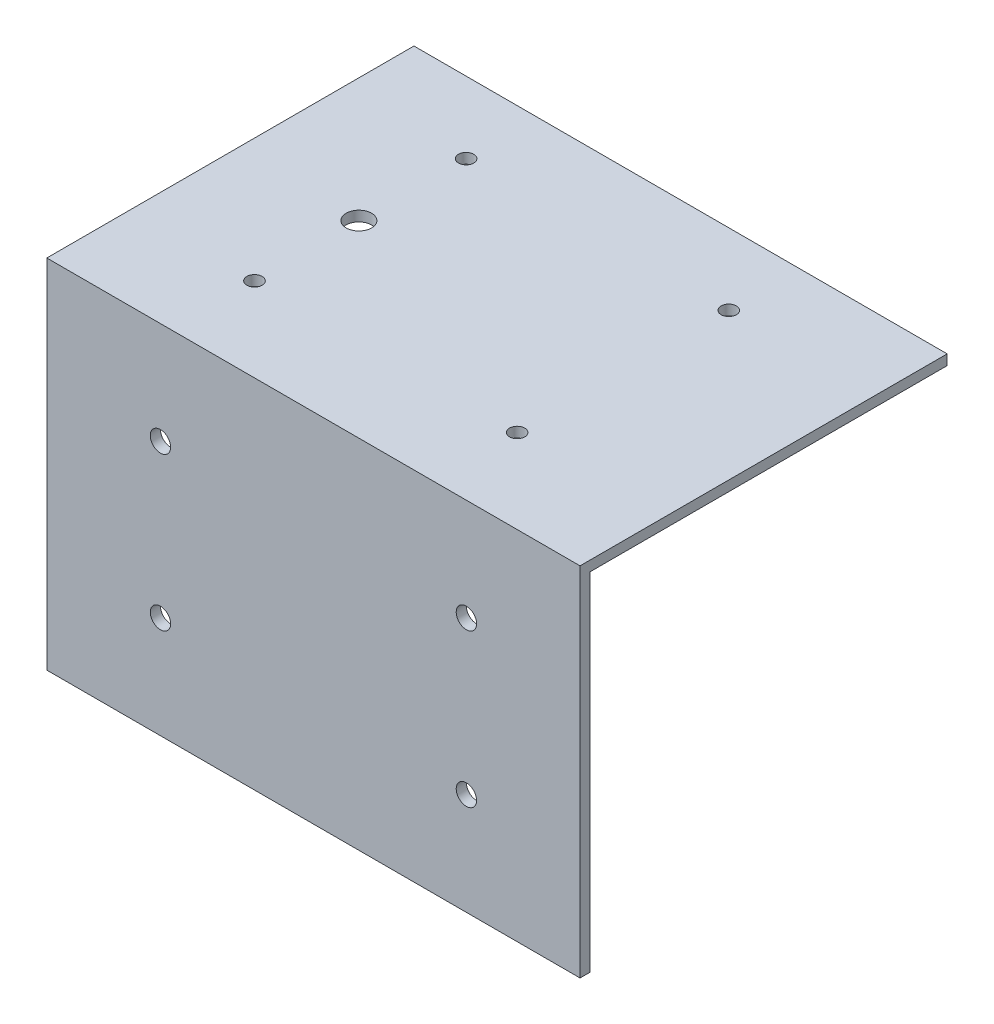
from build123d import *

# Parameters (mm, degrees)
SKETCH1_W           = 100
SKETCH1_H           = 70
SKETCH1_R           = 1.5
SKETCH1_R_2         = 2.5
BOSS_EXTRUDE1_DEPTH = 2
SKETCH2_W           = 70
SKETCH2_H           = 2
BOSS_EXTRUDE2_DEPTH = 70
SKETCH3_W           = 70
SKETCH3_H           = 2
BOSS_EXTRUDE3_DEPTH = 4.57
SKETCH4_W           = 34.57
SKETCH4_H           = 2
BOSS_EXTRUDE4_DEPTH = 70
SKETCH5_R           = 2
CUT_EXTRUDE1_DEPTH  = 10


with BuildPart() as part:
    # Sketch1 → Boss-Extrude1 (new body)
    with BuildSketch(Plane(origin=(0, 0, 0), x_dir=(1, 0, 0), z_dir=(0, 1, 0))):
        Rectangle(SKETCH1_W, SKETCH1_H)
        with Locations((25.755, 20.98)):
            Circle(SKETCH1_R, mode=Mode.SUBTRACT)
        with Locations((-25.755, 20.98)):
            Circle(SKETCH1_R, mode=Mode.SUBTRACT)
        with Locations((25.755, -20.52)):
            Circle(SKETCH1_R, mode=Mode.SUBTRACT)
        with Locations((-25.755, -20.52)):
            Circle(SKETCH1_R, mode=Mode.SUBTRACT)
        with Locations((-25.755, -0.05)):
            Circle(SKETCH1_R_2, mode=Mode.SUBTRACT)
    extrude(amount=BOSS_EXTRUDE1_DEPTH)

    # Sketch2 → Boss-Extrude2 (add)
    with BuildSketch(Plane(origin=(0, 2, 0), x_dir=(1, 0, 0), z_dir=(0, 1, 0))):
        with Locations((-15, -36)):
            Rectangle(SKETCH2_W, SKETCH2_H)
    extrude(amount=-BOSS_EXTRUDE2_DEPTH)

    # Sketch3 → Boss-Extrude3 (add)
    with BuildSketch(Plane(origin=(50, 0, 0), x_dir=(0, 0, -1), z_dir=(1, 0, 0))):
        with Locations((0, 1)):
            Rectangle(SKETCH3_W, SKETCH3_H)
    extrude(amount=BOSS_EXTRUDE3_DEPTH)

    # Sketch4 → Boss-Extrude4 (add)
    with BuildSketch(Plane(origin=(0, 2, 0), x_dir=(1, 0, 0), z_dir=(0, 1, 0))):
        with Locations((37.285, -36)):
            Rectangle(SKETCH4_W, SKETCH4_H)
    extrude(amount=-BOSS_EXTRUDE4_DEPTH)

    # Sketch5 → Cut-Extrude1 (cut)
    with BuildSketch(Plane(origin=(0, 0, 35), x_dir=(-1, 0, 0), z_dir=(0, 0, -1))):
        with Locations((-32.285, -18)):
            Circle(SKETCH5_R)
        with Locations((27.715, -48)):
            Circle(SKETCH5_R)
        with Locations((-32.285, -48)):
            Circle(SKETCH5_R)
        with Locations((27.715, -18)):
            Circle(SKETCH5_R)
    extrude(amount=-CUT_EXTRUDE1_DEPTH, mode=Mode.SUBTRACT)


solid = part.part
